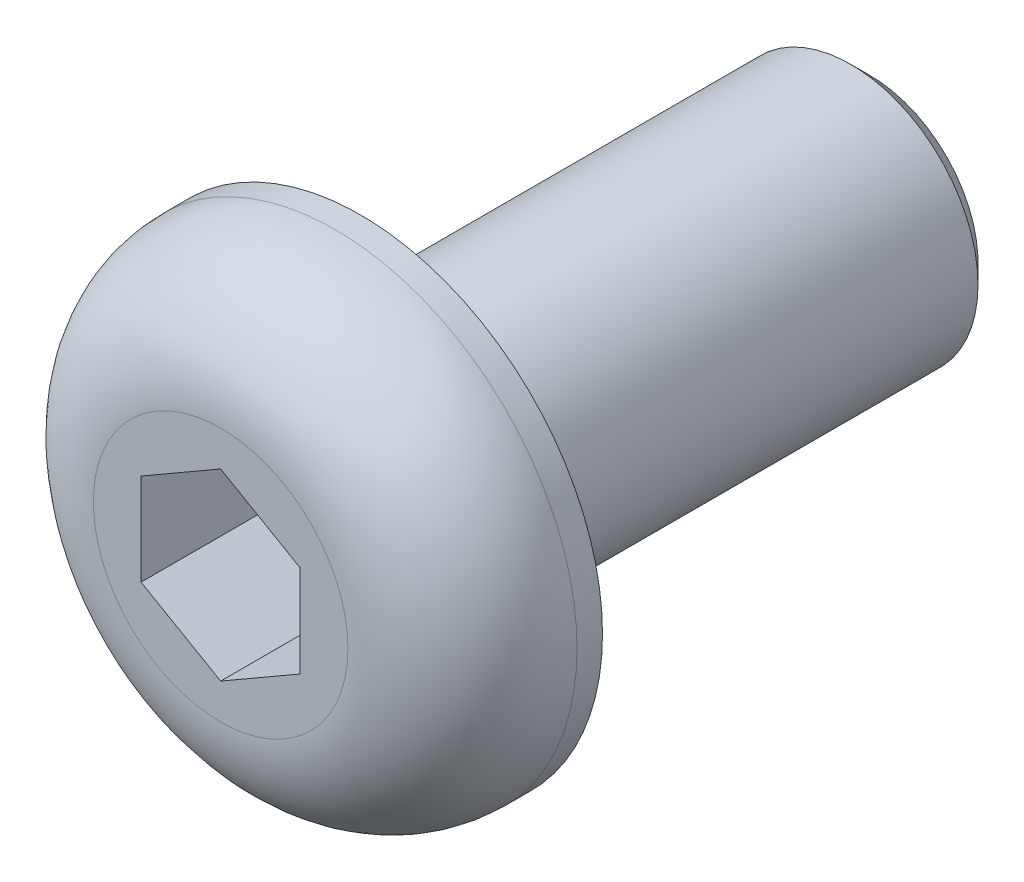
from build123d import *

# Parameters (mm, degrees)
SKETCH1_R           = 3.8
BOSS_EXTRUDE1_DEPTH = 2.2
SKETCH2_R           = 2
BOSS_EXTRUDE2_DEPTH = 8
CHAMFER1_SIZE       = 0.3
CUT_EXTRUDE1_DEPTH  = 2
FILLET1_R           = 1.8


with BuildPart() as part:
    # Sketch1 → Boss-Extrude1 (new body)
    with BuildSketch(Plane.XY):
        Circle(SKETCH1_R)
    extrude(amount=BOSS_EXTRUDE1_DEPTH)

    # Sketch2 → Boss-Extrude2 (add)
    with BuildSketch(Plane(origin=(0, 0, 0), x_dir=(-1, 0, 0), z_dir=(0, 0, -1))):
        Circle(SKETCH2_R)
    extrude(amount=BOSS_EXTRUDE2_DEPTH)

    # Chamfer1
    chamfer1_edges = [part.edges().sort_by_distance(p)[0] for p in [
        (2, 0, -8),
    ]]
    chamfer(chamfer1_edges, length=CHAMFER1_SIZE)

    # Sketch3 → Cut-Extrude1 (cut)
    with BuildSketch(Plane.XY.offset(2.2)):
        Polygon((0, 1.443375673), (-1.25, 0.721687836), (-1.25, -0.721687836), (0, -1.443375673), (1.25, -0.721687836), (1.25, 0.721687836), align=None)
    extrude(amount=-CUT_EXTRUDE1_DEPTH, mode=Mode.SUBTRACT)

    # Fillet1
    fillet1_edges = [part.edges().sort_by_distance(p)[0] for p in [
        (-3.8, 0, 2.2),
    ]]
    fillet(fillet1_edges, radius=FILLET1_R)


solid = part.part
